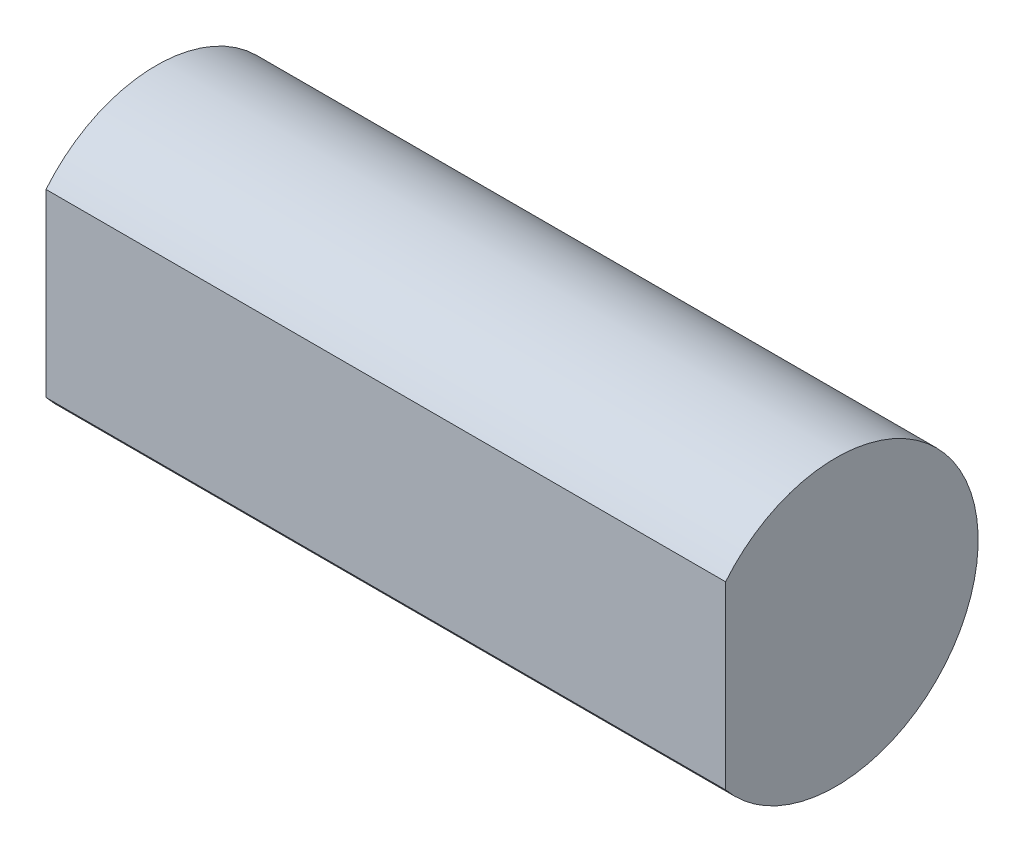
from build123d import *

# Parameters (mm, degrees)
SALIENTE_EXTRUIR1_DEPTH = 18.5


with BuildPart() as part:
    # Croquis1 → Saliente-Extruir1 (new body)
    with BuildSketch(Plane.YZ):
        with BuildLine():
            Line((2.452677109, 3), (-2.452677109, 3))
            ThreePointArc((-2.452677109, 3), (0, -3.875), (2.452677109, 3))
        make_face()
    extrude(amount=SALIENTE_EXTRUIR1_DEPTH)


solid = part.part
